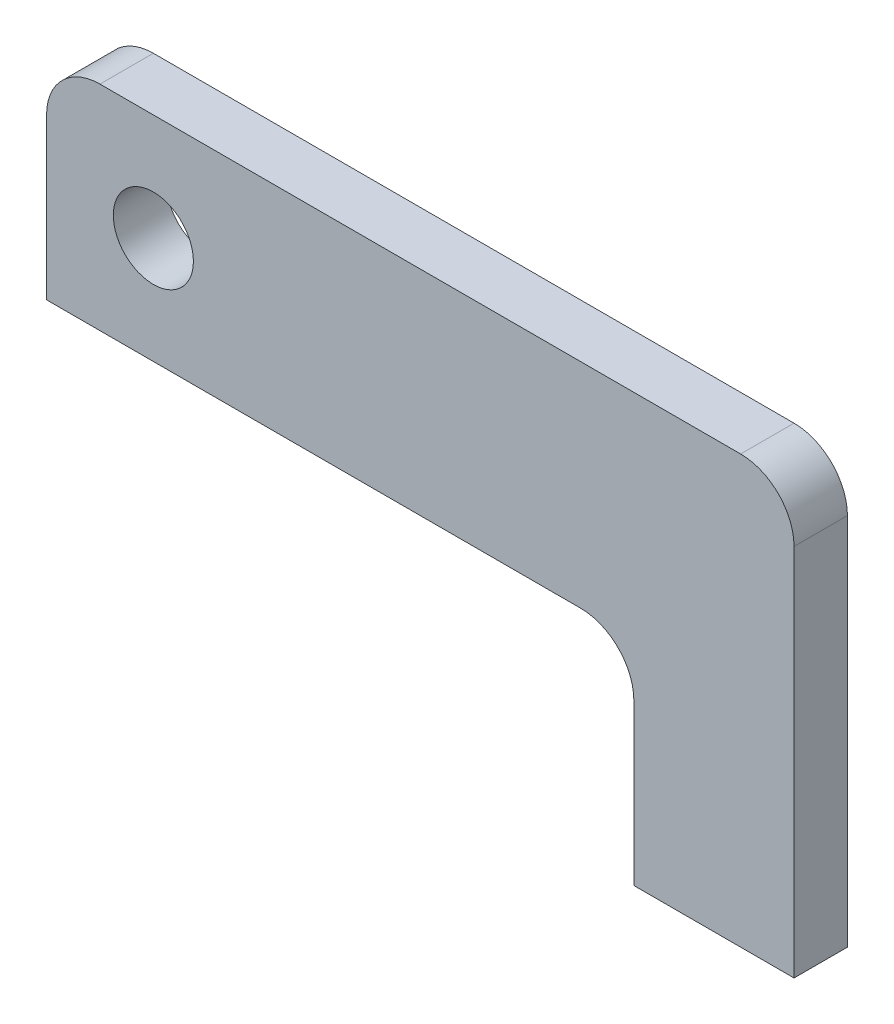
from build123d import *

# Parameters (mm, degrees)
SKETCH4_R           = 4.7625
BOSS_EXTRUDE2_DEPTH = 6.35


with BuildPart() as part:
    # Sketch4 → Boss-Extrude2 (new body)
    with BuildSketch(Plane.XY):
        with BuildLine():
            Line((0, 0), (0, 19.05))
            ThreePointArc((0, 19.05), (1.859871939, 23.540128061), (6.35, 25.4))
            Line((6.35, 25.4), (82.55, 25.4))
            ThreePointArc((82.55, 25.4), (87.040128061, 23.540128061), (88.9, 19.05))
            Line((88.9, 19.05), (88.9, -25.4))
            Line((88.9, -25.4), (69.85, -25.4))
            Line((69.85, -25.4), (69.85, -6.35))
            ThreePointArc((69.85, -6.35), (67.990128061, -1.859871939), (63.5, 0))
            Line((63.5, 0), (0, 0))
        make_face()
        with Locations((12.7, 12.7)):
            Circle(SKETCH4_R, mode=Mode.SUBTRACT)
    extrude(amount=BOSS_EXTRUDE2_DEPTH)


solid = part.part
